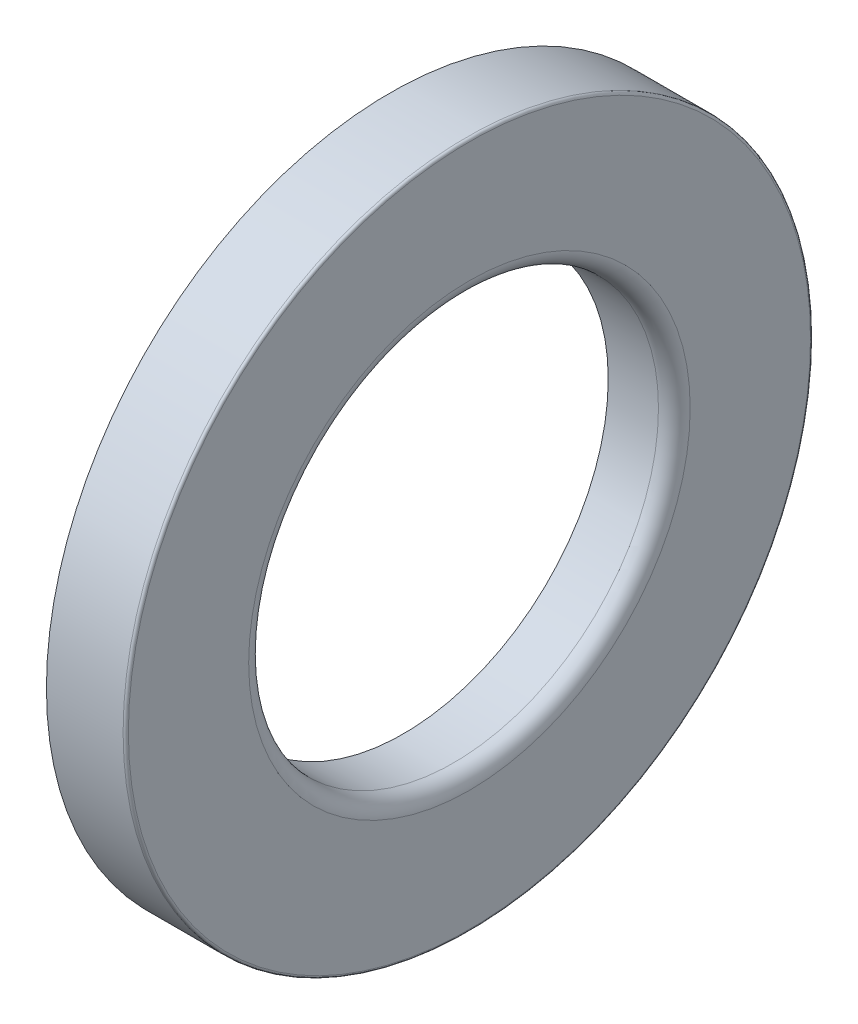
from build123d import *


with BuildPart() as part:
    # Esquisse1 → Révolution1 (revolve)
    with BuildSketch(Plane.XY, mode=Mode.PRIVATE) as r_volution1_sk:
        with BuildLine():
            Line((0, 8.75), (0, 12))
            ThreePointArc((0, 12), (-0.146446609, 12.353553391), (-0.5, 12.5))
            Line((-0.5, 12.5), (-2.5, 12.5))
            Line((-2.5, 12.5), (-2.5, 13))
            Line((-2.5, 13), (0.4, 13))
            ThreePointArc((0.4, 13), (0.470710678, 12.970710678), (0.5, 12.9))
            Line((0.5, 12.9), (0.5, 8.35))
            ThreePointArc((0.5, 8.35), (0.324264069, 7.925735931), (-0.1, 7.75))
            Line((-0.1, 7.75), (-2, 7.75))
            Line((-2, 7.75), (-2, 8.25))
            Line((-2, 8.25), (-0.5, 8.25))
            ThreePointArc((-0.5, 8.25), (-0.146446609, 8.396446609), (0, 8.75))
        make_face()
    revolve(r_volution1_sk.sketch.rotate(Axis((-5.956424792, 0, 0), (1, 0, 0)), 90), axis=Axis((-5.956424792, 0, 0), (1, 0, 0)))  # turned: the seam where the file's is


solid = part.part
